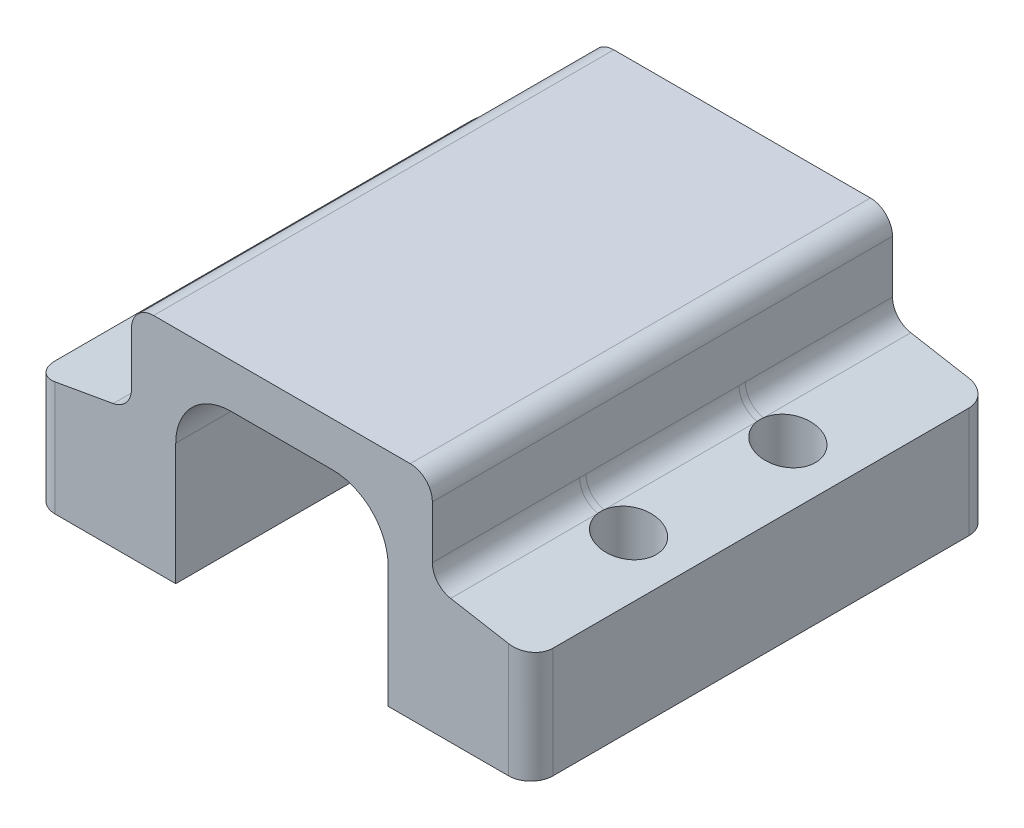
from build123d import *

# Parameters (mm, degrees)
BOSS_EXTRUDE1_DEPTH      = 3.556
BOSS_EXTRUDE1_DEPTH_BACK = 22.86
BOSS_EXTRUDE2_DEPTH      = 13.462
BOSS_EXTRUDE3_START      = -1.27
BOSS_EXTRUDE3_DEPTH      = 1.905
FILLET1_R                = 1.27
BOSS_EXTRUDE4_DEPTH      = 8.509
CUT_EXTRUDE1_DEPTH       = 7.874


with BuildPart() as part:
    # Sketch1 → Boss-Extrude1 (new body, two sides)
    with BuildSketch(Plane.XY) as boss_extrude1_sk:
        Polygon((-6.096, 10.16), (6.096, 10.16), (6.096, 0), (14.2875, 0), (14.2875, 6.35), (8.636, 7.346511931), (8.636, 12.7), (-8.636, 12.7), (-8.636, 7.346511931), (-14.2875, 6.35), (-14.2875, 0), (-6.096, 0), align=None)
    extrude(amount=BOSS_EXTRUDE1_DEPTH)
    extrude(boss_extrude1_sk.sketch, amount=-BOSS_EXTRUDE1_DEPTH_BACK)

    # Sketch2 → Boss-Extrude2 (add)
    with BuildSketch(Plane.XY.offset(3.556)):
        with BuildLine():
            Line((2.921, 10.16), (6.096, 10.16))
            Line((6.096, 10.16), (6.096, 6.985))
            ThreePointArc((6.096, 6.985), (5.16606403, 9.23006403), (2.921, 10.16))
        make_face()
        with BuildLine():
            Line((-6.096, 10.16), (-6.096, 6.985))
            ThreePointArc((-6.096, 6.985), (-5.16606403, 9.23006403), (-2.921, 10.16))
            Line((-2.921, 10.16), (-6.096, 10.16))
        make_face()
    extrude(amount=-BOSS_EXTRUDE2_DEPTH)

    # Sketch3 → Boss-Extrude3 (add)
    with BuildSketch(Plane.XY.offset(-9.906).offset(BOSS_EXTRUDE3_START)):
        with BuildLine():
            Line((-6.096, 10.16), (-6.096, 6.985))
            ThreePointArc((-6.096, 6.985), (-5.16606403, 9.23006403), (-2.921, 10.16))
            Line((-2.921, 10.16), (-6.096, 10.16))
        make_face()
    extrude(amount=-BOSS_EXTRUDE3_DEPTH)

    # Sketch6 → Cut-Revolve1 (revolve, cut)
    with BuildSketch(Plane.XY.offset(-5.08)):
        Polygon((11.262482277, -1.27), (12.849982277, -1.27), (12.849982277, 6.60347316), (12.849982277, 9.423392242), (11.262482277, 9.423392242), (11.262482277, 6.883392242), align=None)
    cut_revolve1 = revolve(axis=Axis((11.262482277, -1.27, -5.08), (0, -1, 0)), mode=Mode.SUBTRACT)

    # Mirror1: Cut-Revolve1 across plane
    add(cut_revolve1.mirror(Plane(origin=(0, 0, 0), x_dir=(0, 0, 1), z_dir=(1, 0, 0))), mode=Mode.SUBTRACT)

    # Mirror2: Cut-Revolve1 across plane
    add(cut_revolve1.mirror(Plane.XY.offset(-9.652)), mode=Mode.SUBTRACT)

    # Mirror2 copy 1 sketch → Mirror2 copy 1 (revolve, cut)
    with BuildSketch(Plane(origin=(0, 0, -14.224), x_dir=(-1, 0, 0), z_dir=(0, 0, -1))):
        Polygon((11.262482277, -1.27), (12.849982277, -1.27), (12.849982277, 6.60347316), (12.849982277, 9.423392242), (11.262482277, 9.423392242), (11.262482277, 6.883392242), align=None)
    revolve(axis=Axis((-11.262482277, -1.27, -14.224), (0, -1, 0)), mode=Mode.SUBTRACT)

    # Fillet1
    fillet1_edges = [part.edges().sort_by_distance(p)[0] for p in [
        (14.2875, 3.175, 3.556),
        (-8.636, 7.346511931, -9.652),
        (-8.636, 12.7, -9.652),
        (8.636, 12.7, -9.652),
        (8.636, 7.346511931, -9.652),
        (-14.2875, 3.175, -22.86),
        (14.2875, 3.175, -22.86),
        (-14.2875, 3.175, 3.556),
    ]]
    fillet(fillet1_edges, radius=FILLET1_R)

    # Sketch4 → Boss-Extrude4 (add)
    with BuildSketch(Plane.XY.offset(-13.081)):
        with BuildLine():
            Line((-6.096, 10.16), (-6.096, 6.985))
            ThreePointArc((-6.096, 6.985), (-5.16606403, 9.23006403), (-2.921, 10.16))
            Line((-2.921, 10.16), (-6.096, 10.16))
        make_face()
    extrude(amount=-BOSS_EXTRUDE4_DEPTH)

    # Sketch9 → Cut-Extrude1 (cut)
    with BuildSketch(Plane.XY.offset(-12.446)):
        Polygon((-6.096, 6.985), (-5.987323019, 7.808582504), (-5.675836906, 8.563448168), (-5.16606403, 9.23006403), (-4.513044207, 9.732002047), (-3.747031782, 10.05066412), (-2.921, 10.16), (-6.096, 10.16), align=None)
    extrude(amount=-CUT_EXTRUDE1_DEPTH, mode=Mode.SUBTRACT)


solid = part.part
